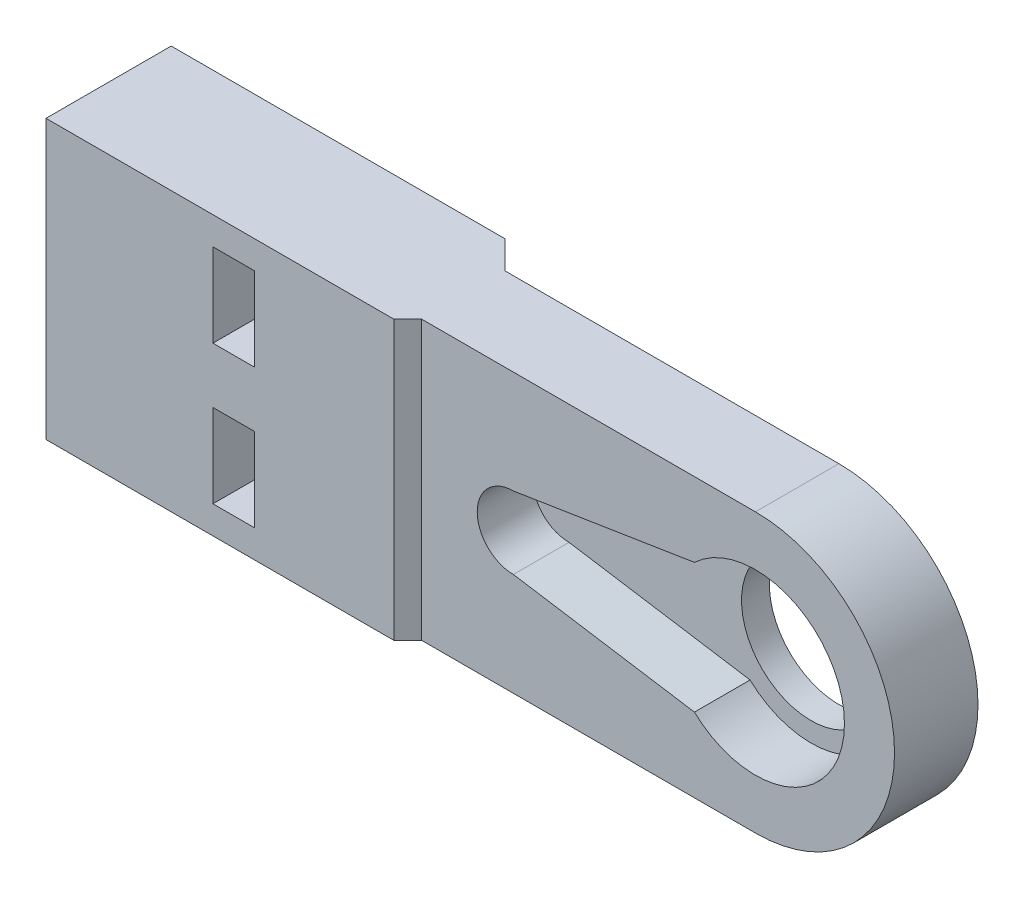
from build123d import *

# Parameters (mm, degrees)
EXTRUDE_1_DEPTH     = 6
CUT_EXTRUDE_1_DEPTH = 4
SKETCH_3_R          = 1.5
CUT_EXTRUDE_2_DEPTH = 20
EXTRUDE_2_DEPTH     = 10
EXTRUDE_3_DEPTH     = 10
SKETCH_5_W          = 3
SKETCH_5_H          = 6
CUT_EXTRUDE_3_DEPTH = 52.778373864


with BuildPart() as part:
    # Эскиз1 → Бобышка-Вытянуть1 (new body)
    with BuildSketch(Plane.XY):
        with BuildLine():
            Line((0, 10), (0, 5))
            ThreePointArc((0, 5), (3.535533906, 3.535533906), (5, 0))
            ThreePointArc((5, 0), (3.535533906, -3.535533906), (0, -5))
            Line((0, -5), (0, -10))
            ThreePointArc((0, -10), (7.071067812, -7.071067812), (10, 0))
            ThreePointArc((10, 0), (7.071067812, 7.071067812), (0, 10))
        make_face()
        with BuildLine():
            ThreePointArc((0, -5), (-3.535533906, -3.535533906), (-5, 0))
            Line((-5, 0), (-10, 0))
            ThreePointArc((-10, 0), (-7.071067812, -7.071067812), (0, -10))
            Line((0, -10), (0, -5))
        make_face()
        with BuildLine():
            Line((-10, 0), (-5, 0))
            ThreePointArc((-5, 0), (-3.535533906, 3.535533906), (0, 5))
            Line((0, 5), (0, 10))
            ThreePointArc((0, 10), (-7.071067812, 7.071067812), (-10, 0))
        make_face()
        with BuildLine():
            ThreePointArc((0, -10), (-7.071067812, -7.071067812), (-10, 0))
            Line((-10, 0), (-50, 0))
            Line((-50, 0), (-50, -10))
            Line((-50, -10), (0, -10))
        make_face()
        with BuildLine():
            Line((-50, 0), (-10, 0))
            ThreePointArc((-10, 0), (-7.071067812, 7.071067812), (0, 10))
            Line((0, 10), (-50, 10))
            Line((-50, 10), (-50, 0))
        make_face()
    extrude(amount=EXTRUDE_1_DEPTH)

    # Эскиз2 → Вырез-Вытянуть1 (cut)
    with BuildSketch(Plane.XY.offset(6)):
        with BuildLine():
            Line((-4.385462329, 4.661300265), (-17.4, 2.6))
            ThreePointArc((-17.4, 2.6), (-20, 0), (-17.4, -2.6))
            Line((-17.4, -2.6), (-4.385462329, -4.661300265))
            ThreePointArc((-4.385462329, -4.661300265), (6.4, 0), (-4.385462329, 4.661300265))
        make_face()
    extrude(amount=-CUT_EXTRUDE_1_DEPTH, mode=Mode.SUBTRACT)

    # Эскиз3 → Вырез-Вытянуть2 (cut)
    with BuildSketch(Plane.ZY.offset(50)):
        with Locations((2.2, 5)):
            Circle(SKETCH_3_R)
        with Locations((2.2, -5)):
            Circle(SKETCH_3_R)
    extrude(amount=-CUT_EXTRUDE_2_DEPTH, mode=Mode.SUBTRACT)

    # Эскиз4 → Бобышка-Вытянуть2 (add, symmetric)
    with BuildSketch(Plane(origin=(0, 0, 0), x_dir=(1, 0, 0), z_dir=(0, 1, 0))):
        Polygon((-50, 0), (-24, 0), (-26, 2), (-50, 2), align=None)
    extrude(amount=EXTRUDE_2_DEPTH, both=True)

    # Эскиз6 → Бобышка-Вытянуть3 (add, symmetric)
    with BuildSketch(Plane(origin=(0, 0, 0), x_dir=(1, 0, 0), z_dir=(0, 1, 0))):
        Polygon((-24, -6), (-50, -6), (-50, -7), (-25, -7), align=None)
    extrude(amount=EXTRUDE_3_DEPTH, both=True)

    # Эскиз5 → Вырез-Вытянуть3 (cut, through all)
    with BuildSketch(Plane(origin=(0, 0, -2), x_dir=(-1, 0, 0), z_dir=(0, 0, -1))):
        with Locations((36.5, -5)):
            Rectangle(SKETCH_5_W, SKETCH_5_H)
        with Locations((36.5, 5)):
            Rectangle(SKETCH_5_W, SKETCH_5_H)
    extrude(amount=-CUT_EXTRUDE_3_DEPTH, mode=Mode.SUBTRACT)


solid = part.part
